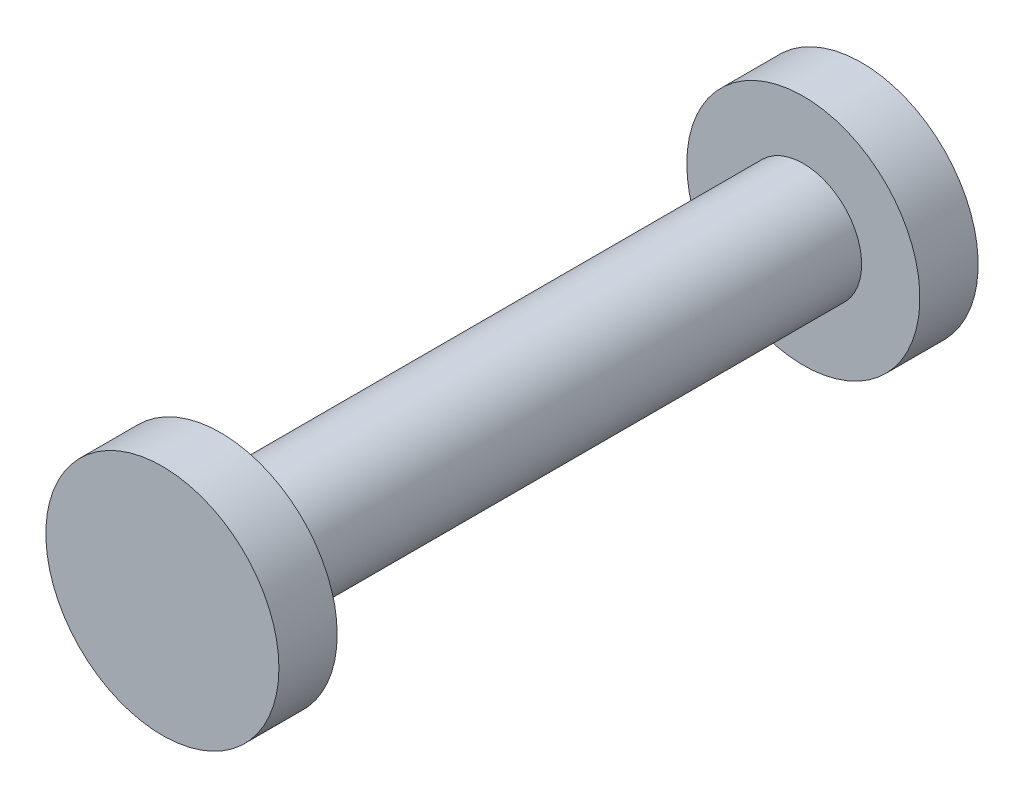
from build123d import *

# Parameters (mm, degrees)
SKETCH2_R           = 5
BOSS_EXTRUDE1_DEPTH = 50
SKETCH3_R           = 10
BOSS_EXTRUDE2_DEPTH = 5
SKETCH4_R           = 10
BOSS_EXTRUDE3_DEPTH = 5


with BuildPart() as part:
    # Sketch2 → Boss-Extrude1 (new body)
    with BuildSketch(Plane.XY):
        Circle(SKETCH2_R)
    extrude(amount=BOSS_EXTRUDE1_DEPTH)

    # Sketch3 → Boss-Extrude2 (add)
    with BuildSketch(Plane(origin=(0, 0, 0), x_dir=(-1, 0, 0), z_dir=(0, 0, -1))):
        Circle(SKETCH3_R)
    extrude(amount=BOSS_EXTRUDE2_DEPTH)

    # Sketch4 → Boss-Extrude3 (add)
    with BuildSketch(Plane.XY.offset(50)):
        Circle(SKETCH4_R)
    extrude(amount=BOSS_EXTRUDE3_DEPTH)


solid = part.part
